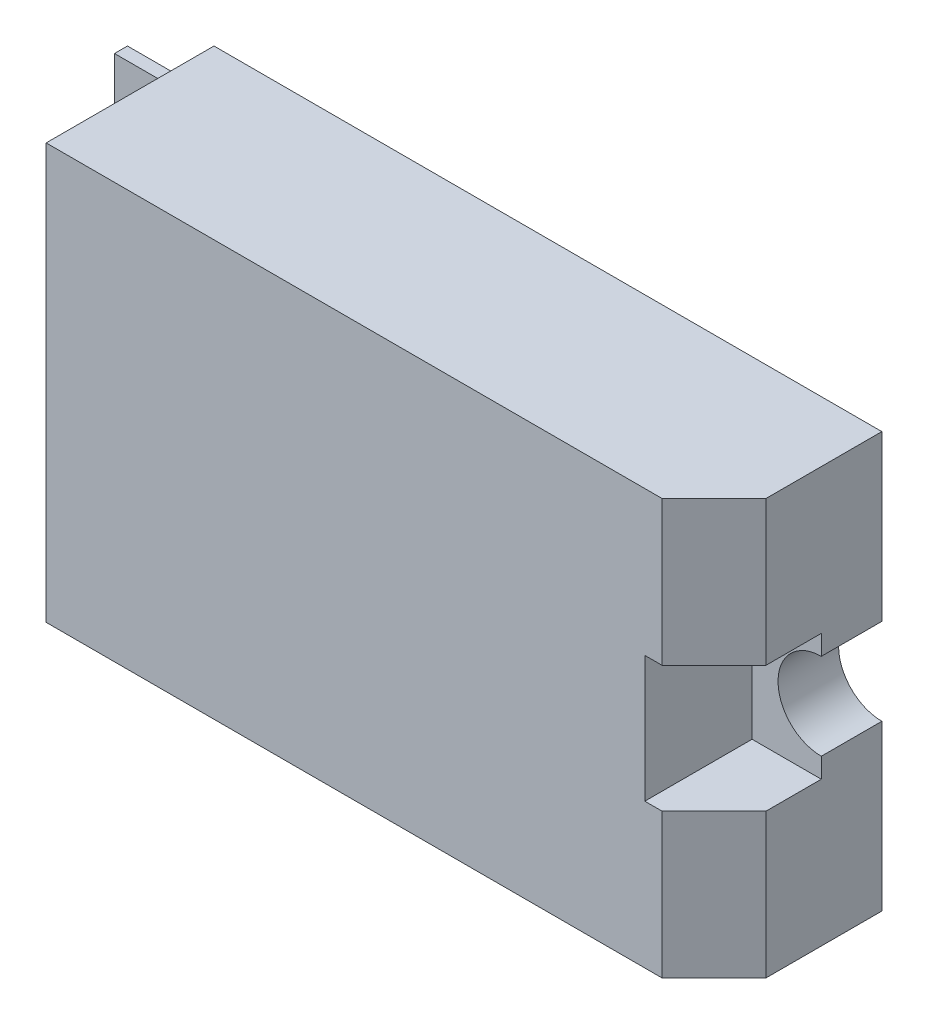
from build123d import *

# Parameters (mm, degrees)
SKETCH_1_W          = 38.6
SKETCH_1_H          = 24
EXTRUDE_1_DEPTH     = 9.7
SKETCH_2_W          = 0.75
SKETCH_2_H          = 21
EXTRUDE_2_DEPTH     = 4
CHAMFER_1_SIZE      = 3
SKETCH_3_W          = 4
SKETCH_3_H          = 7.3
CUT_EXTRUDE_1_DEPTH = 6.2
SKETCH_4_R          = 2.5
CUT_EXTRUDE_2_DEPTH = 4.5


with BuildPart() as part:
    # 草图1 → 凸台-拉伸1 (new body)
    with BuildSketch(Plane(origin=(28.693608134, -23.996349429, -44.112502039), x_dir=(1, 0, 0), z_dir=(0, 0, 1))):
        with Locations((-46.492248891, -33.863193326)):
            Rectangle(SKETCH_1_W, SKETCH_1_H)
    extrude(amount=EXTRUDE_1_DEPTH)

    # 草图2 → 凸台-拉伸2 (add)
    with BuildSketch(Plane.ZY.offset(37.098640757)):
        with Locations((-42.737502039, -57.859542755)):
            Rectangle(SKETCH_2_W, SKETCH_2_H)
    extrude(amount=EXTRUDE_2_DEPTH)

    # 倒角1
    chamfer_1_edges = [part.edges().sort_by_distance(p)[0] for p in [
        (1.501359243, -57.859542755, -34.412502039),
    ]]
    chamfer(chamfer_1_edges, length=CHAMFER_1_SIZE)

    # 草图3 → 切除-拉伸1 (cut)
    with BuildSketch(Plane.XY.offset(-34.412502039)):
        with Locations((-0.498640757, -57.859542755)):
            Rectangle(SKETCH_3_W, SKETCH_3_H)
    extrude(amount=-CUT_EXTRUDE_1_DEPTH, mode=Mode.SUBTRACT)

    # 草图4 → 切除-拉伸2 (cut, through all)
    with BuildSketch(Plane.XY.offset(-40.612502039)):
        with Locations((1.501359243, -57.859542755)):
            Circle(SKETCH_4_R)
    extrude(amount=-CUT_EXTRUDE_2_DEPTH, mode=Mode.SUBTRACT)


solid = part.part
